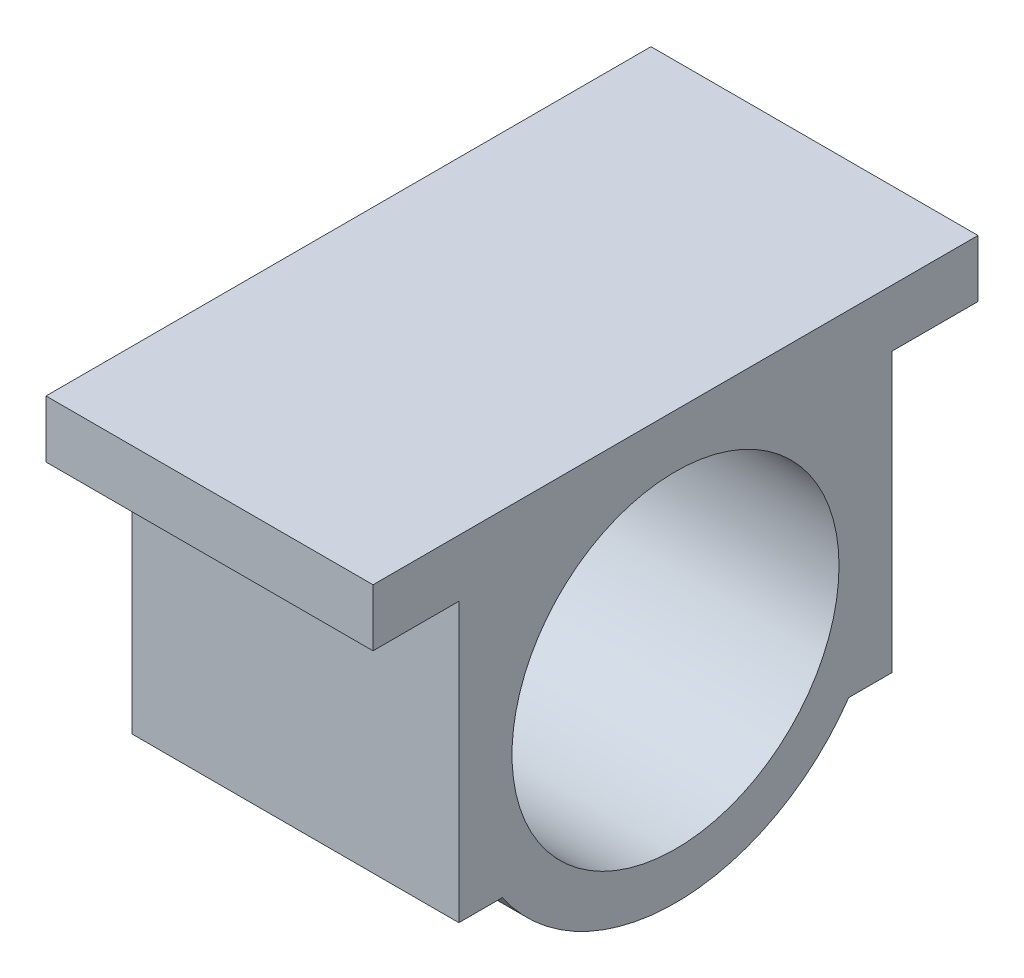
from build123d import *

# Parameters (mm, degrees)
SKETCH1_R           = 40
BOSS_EXTRUDE1_DEPTH = 40


with BuildPart() as part:
    # Sketch1 → Boss-Extrude1 (new, symmetric)
    with BuildSketch(Plane(origin=(0, 0, 0), x_dir=(0, 0, -1), z_dir=(1, 0, 0))):
        with BuildLine():
            Line((-53, -29.1), (-42.369210519, -29.1))
            ThreePointArc((-42.369210519, -29.1), (0, -51.4), (42.369210519, -29.1))
            Line((42.369210519, -29.1), (53, -29.1))
            Line((53, -29.1), (53, 39))
            Line((53, 39), (74, 39))
            Line((74, 39), (74, 53))
            Line((74, 53), (-74, 53))
            Line((-74, 53), (-74, 39))
            Line((-74, 39), (-53, 39))
            Line((-53, 39), (-53, -29.1))
        make_face()
        Circle(SKETCH1_R, mode=Mode.SUBTRACT)
    extrude(amount=BOSS_EXTRUDE1_DEPTH, both=True)


solid = part.part
